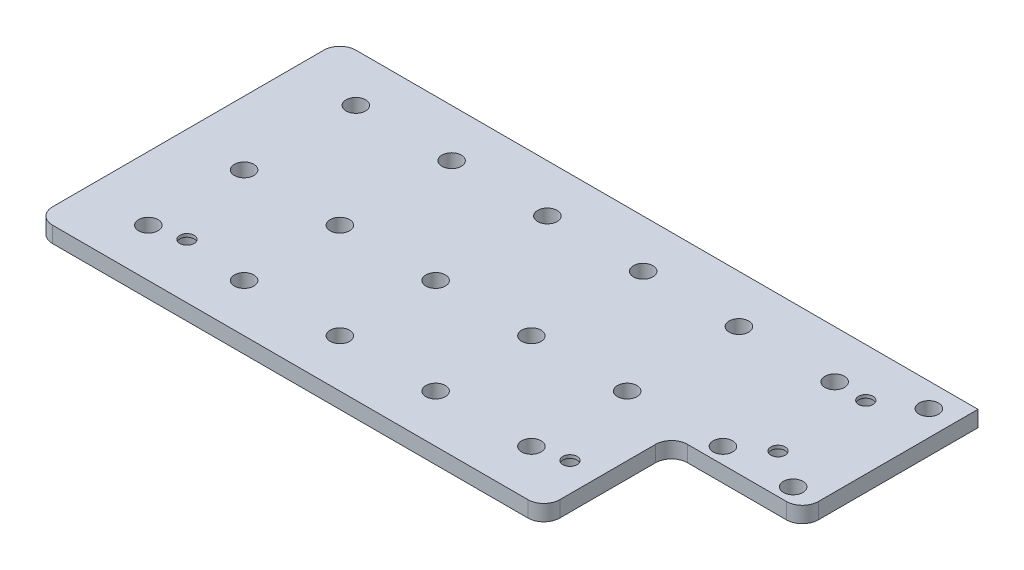
from build123d import *

# Parameters (mm, degrees)
SKETCH1_W                     = 199.9
SKETCH1_H                     = 95
BOSS_EXTRUDE1_DEPTH           = 5
CBORE_FOR_M4_SHCS1_AT_2_COUNT = 2
CBORE_FOR_M4_SHCS1_AT_2_PITCH = 69.462381906
CBORE_FOR_M4_SHCS1_AT_3_COUNT = 2
CBORE_FOR_M4_SHCS1_AT_3_PITCH = 162.557751276
CBORE_FOR_M4_SHCS1_AT_4_COUNT = 2
CBORE_FOR_M4_SHCS1_AT_4_PITCH = 27.5
F_6_1_6_1_DIAMETER_HOLE2_D    = 6.1
LPATTERN1_COUNT               = 2
LPATTERN1_PITCH               = 35
SKETCH6_W                     = 41
SKETCH6_H                     = 40
CUT_EXTRUDE1_DEPTH            = 6
LPATTERN2_COUNT               = 2
LPATTERN2_PITCH               = 65
FILLET1_R                     = 5
F_6_1_6_1_DIAMETER_HOLE1_D    = 6.1


with BuildPart() as part:
    # Sketch1 → Boss-Extrude1 (new body)
    with BuildSketch(Plane(origin=(0, 0, 0), x_dir=(1, 0, 0), z_dir=(0, 1, 0))):
        with Locations((99.95, -47.5)):
            Rectangle(SKETCH1_W, SKETCH1_H)
    extrude(amount=BOSS_EXTRUDE1_DEPTH)

    # Sketch3 → CBORE for M4 SHCS1 (revolve, cut)
    with BuildSketch(Plane(origin=(179.9, 0, 15.15), x_dir=(0, 0, -1), z_dir=(1, 0, 0))):
        Polygon((0, 0), (0, 5), (2.25, 5), (2.25, 4), (4, 4), (4, 0.025), (4.025, 0), align=None)
    cbore_for_m4_shcs1 = revolve(axis=Axis((179.9, -6.35, 15.15), (0, 1, 0)), mode=Mode.SUBTRACT)

    # CBORE for M4 SHCS1 at 2: CBORE for M4 SHCS1 ×2
    with Locations(*[Vector(-0.431888443, 0, 0.901927033) * (i * CBORE_FOR_M4_SHCS1_AT_2_PITCH) for i in range(1, CBORE_FOR_M4_SHCS1_AT_2_COUNT)]):
        add(cbore_for_m4_shcs1, mode=Mode.SUBTRACT)

    # CBORE for M4 SHCS1 at 3: CBORE for M4 SHCS1 ×2
    with Locations(*[Vector(-0.922748985, 0, 0.385401493) * (i * CBORE_FOR_M4_SHCS1_AT_3_PITCH) for i in range(1, CBORE_FOR_M4_SHCS1_AT_3_COUNT)]):
        add(cbore_for_m4_shcs1, mode=Mode.SUBTRACT)

    # CBORE for M4 SHCS1 at 4: CBORE for M4 SHCS1 ×2
    with Locations(*[(0, 0, i * CBORE_FOR_M4_SHCS1_AT_4_PITCH) for i in range(1, CBORE_FOR_M4_SHCS1_AT_4_COUNT)]):
        add(cbore_for_m4_shcs1, mode=Mode.SUBTRACT)

    # Ø6.1 (6.1) Diameter Hole2 (through all)
    with Locations(Plane(origin=(0, 5, 0), x_dir=(1, 0, 0), z_dir=(0, 1, 0))):
        with Locations((170, -15), (20, -15), (50, -15), (80, -15), (110, -15), (140, -15)):
            f_6_1_6_1_diameter_hole2 = Hole(F_6_1_6_1_DIAMETER_HOLE2_D / 2)

    # LPattern1: Ø6.1 (6.1) Diameter Hole2 ×2
    with Locations(*[(0, 0, i * LPATTERN1_PITCH) for i in range(1, LPATTERN1_COUNT)]):
        add(f_6_1_6_1_diameter_hole2, mode=Mode.SUBTRACT)

    # Sketch6 → Cut-Extrude1 (cut, through all)
    with BuildSketch(Plane(origin=(0, 5, 0), x_dir=(1, 0, 0), z_dir=(0, 1, 0))):
        with Locations((179.4, -75)):
            Rectangle(SKETCH6_W, SKETCH6_H)
    extrude(amount=-CUT_EXTRUDE1_DEPTH, mode=Mode.SUBTRACT)

    # LPattern2: Ø6.1 (6.1) Diameter Hole2 ×2
    with Locations(*[(0, 0, i * LPATTERN2_PITCH) for i in range(1, LPATTERN2_COUNT)]):
        add(f_6_1_6_1_diameter_hole2, mode=Mode.SUBTRACT)

    # Fillet1
    fillet1_edges = [part.edges().sort_by_distance(p)[0] for p in [
        (199.9, 2.5, 55),
        (158.9, 2.5, 95),
        (158.9, 2.5, 55),
        (0, 2.5, 0),
        (0, 2.5, 95),
    ]]
    fillet(fillet1_edges, radius=FILLET1_R)

    # Ø6.1 (6.1) Diameter Hole1 (through all)
    with Locations(Plane(origin=(0, 5, 0), x_dir=(1, 0, 0), z_dir=(0, 1, 0))):
        with Locations((192, -50), (192, -7.5)):
            Hole(F_6_1_6_1_DIAMETER_HOLE1_D / 2)


solid = part.part
